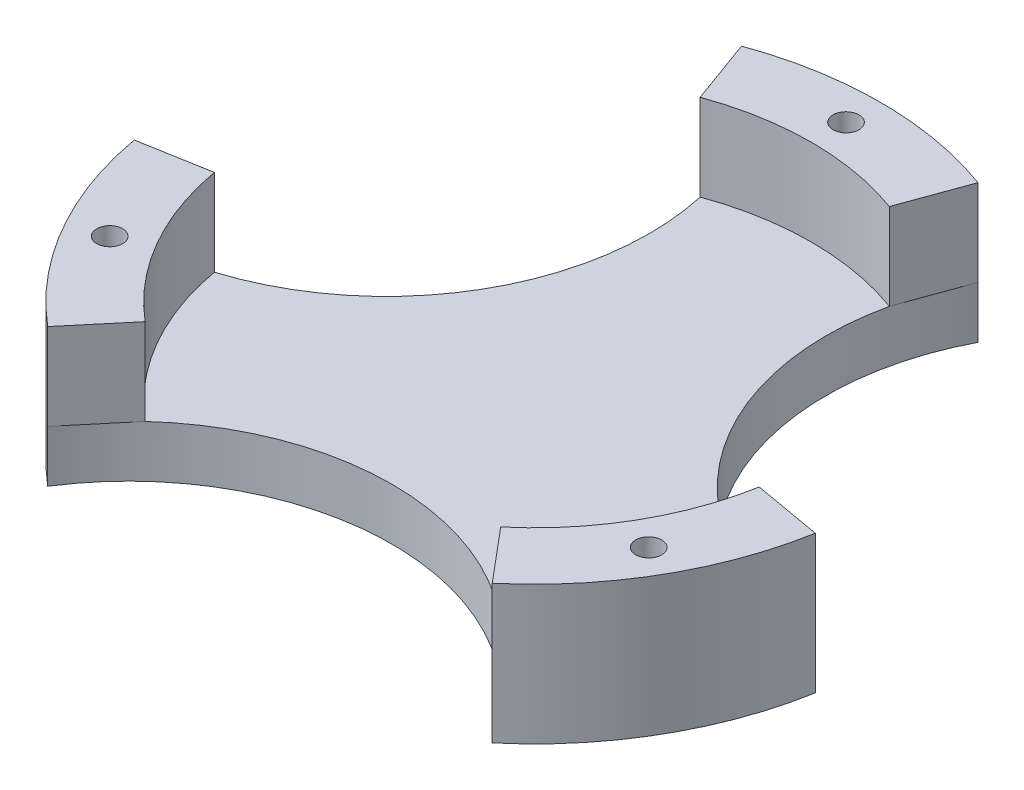
from build123d import *

# Parameters (mm, degrees)
SKETCH1_R           = 40
BOSS_EXTRUDE1_DEPTH = 6
SKETCH2_R           = 1.5
BOSS_EXTRUDE2_DEPTH = 10
SKETCH16_R          = 1.5
CUT_EXTRUDE9_DEPTH  = 17
CIRPATTERN1_COUNT   = 3
SKETCH5_R           = 30.471270003
CUT_EXTRUDE3_DEPTH  = 7
CIRPATTERN2_COUNT   = 3


with BuildPart() as part:
    # Sketch1 → Boss-Extrude1 (new body)
    with BuildSketch(Plane(origin=(0, 0, 0), x_dir=(1, 0, 0), z_dir=(0, 1, 0))):
        Circle(SKETCH1_R)
    extrude(amount=BOSS_EXTRUDE1_DEPTH)

    # Sketch2 → Boss-Extrude2 (add)
    with BuildSketch(Plane(origin=(0, 6, 0), x_dir=(1, 0, 0), z_dir=(0, 1, 0))):
        with BuildLine():
            Line((-13.680805733, 37.587704831), (-10.944644586, 30.070163865))
            ThreePointArc((-10.944644586, 30.070163865), (0, 32), (10.944644586, 30.070163865))
            Line((10.944644586, 30.070163865), (13.680805733, 37.587704831))
            ThreePointArc((13.680805733, 37.587704831), (0, 40), (-13.680805733, 37.587704831))
        make_face()
        with Locations((0, 36)):
            Circle(SKETCH2_R, mode=Mode.SUBTRACT)
    boss_extrude2 = extrude(amount=BOSS_EXTRUDE2_DEPTH)

    # Sketch16 → Cut-Extrude9 (cut, through all)
    with BuildSketch(Plane(origin=(0, 16, 0), x_dir=(1, 0, 0), z_dir=(0, 1, 0))):
        with Locations((0, 36)):
            Circle(SKETCH16_R)
    cut_extrude9 = extrude(amount=-CUT_EXTRUDE9_DEPTH, mode=Mode.SUBTRACT)

    # CirPattern1: Boss-Extrude2, Cut-Extrude9 ×3 about axis
    cirpattern1_axis = Axis((0, 0, 0), (0, 1, 0))
    for i in range(1, CIRPATTERN1_COUNT):
        add(boss_extrude2.rotate(cirpattern1_axis, i * 360 / CIRPATTERN1_COUNT))
        add(cut_extrude9.rotate(cirpattern1_axis, i * 360 / CIRPATTERN1_COUNT), mode=Mode.SUBTRACT)

    # Sketch5 → Cut-Extrude3 (cut, through all)
    with BuildSketch(Plane(origin=(0, 6, 0), x_dir=(1, 0, 0), z_dir=(0, 1, 0))):
        with Locations((40.698571494, 23.497331208)):
            Circle(SKETCH5_R)
    cut_extrude3 = extrude(amount=-CUT_EXTRUDE3_DEPTH, mode=Mode.SUBTRACT)

    # CirPattern2: Cut-Extrude3 ×3 about axis
    cirpattern2_axis = Axis((0, 0, 0), (0, 1, 0))
    for i in range(1, CIRPATTERN2_COUNT):
        add(cut_extrude3.rotate(cirpattern2_axis, i * 360 / CIRPATTERN2_COUNT), mode=Mode.SUBTRACT)


solid = part.part
